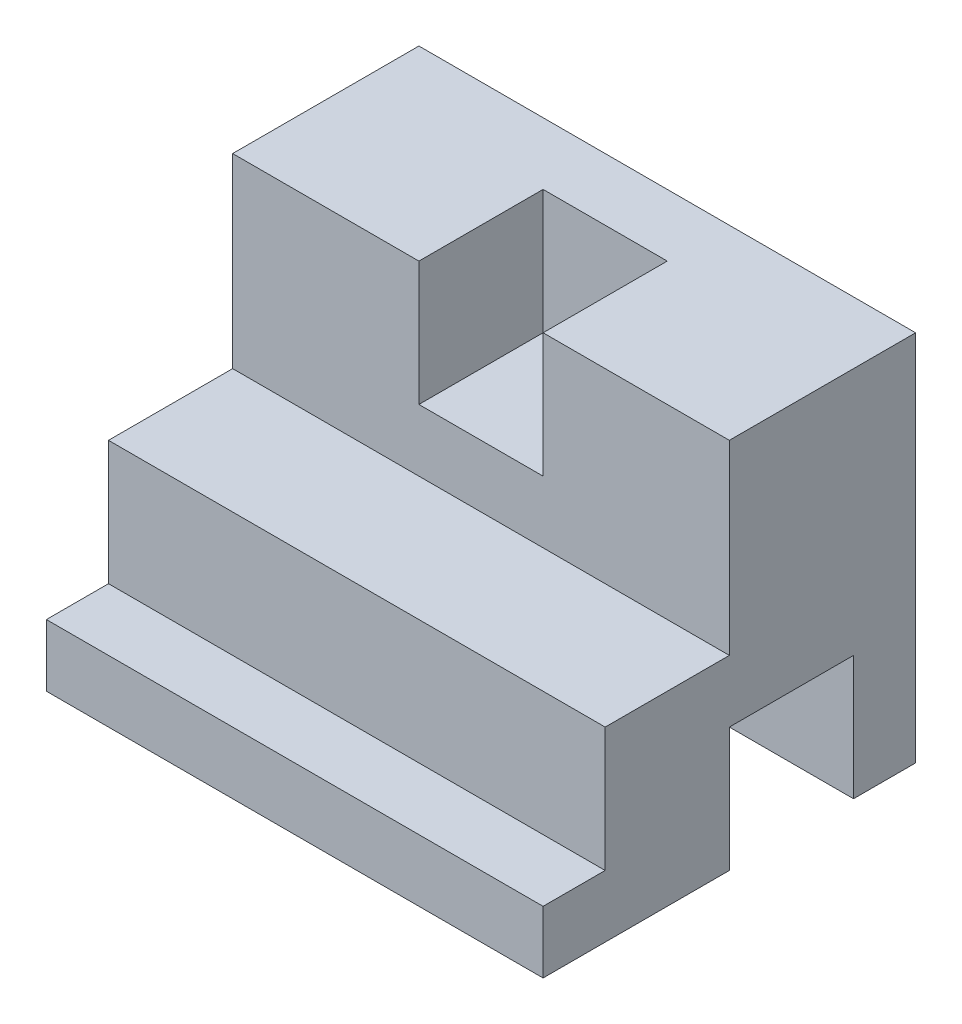
from build123d import *

# Parameters (mm, degrees)
SKETCH1_W           = 203.2
SKETCH1_H           = 152.4
BOSS_EXTRUDE1_DEPTH = 152.4
SKETCH2_W           = 50.8
SKETCH2_H           = 50.8
CUT_EXTRUDE1_DEPTH  = 204.2
SKETCH3_W           = 50.8
SKETCH3_H           = 50.8
CUT_EXTRUDE2_DEPTH  = 50.8


with BuildPart() as part:
    # Sketch1 → Boss-Extrude1 (new body)
    with BuildSketch(Plane.XY):
        with Locations((101.6, 76.2)):
            Rectangle(SKETCH1_W, SKETCH1_H)
    extrude(amount=-BOSS_EXTRUDE1_DEPTH)

    # Sketch2 → Cut-Extrude1 (cut, through all)
    with BuildSketch(Plane(origin=(203.2, 0, 0), x_dir=(0, 0, -1), z_dir=(1, 0, 0))):
        Polygon((0, 25.4), (25.4, 25.4), (25.4, 76.2), (76.2, 76.2), (76.2, 152.4), (0, 152.4), align=None)
        with Locations((101.6, 25.4)):
            Rectangle(SKETCH2_W, SKETCH2_H)
    extrude(amount=-CUT_EXTRUDE1_DEPTH, mode=Mode.SUBTRACT)

    # Sketch3 → Cut-Extrude2 (cut)
    with BuildSketch(Plane(origin=(0, 152.4, 0), x_dir=(1, 0, 0), z_dir=(0, 1, 0))):
        with Locations((101.6, 101.6)):
            Rectangle(SKETCH3_W, SKETCH3_H)
    extrude(amount=-CUT_EXTRUDE2_DEPTH, mode=Mode.SUBTRACT)


solid = part.part
